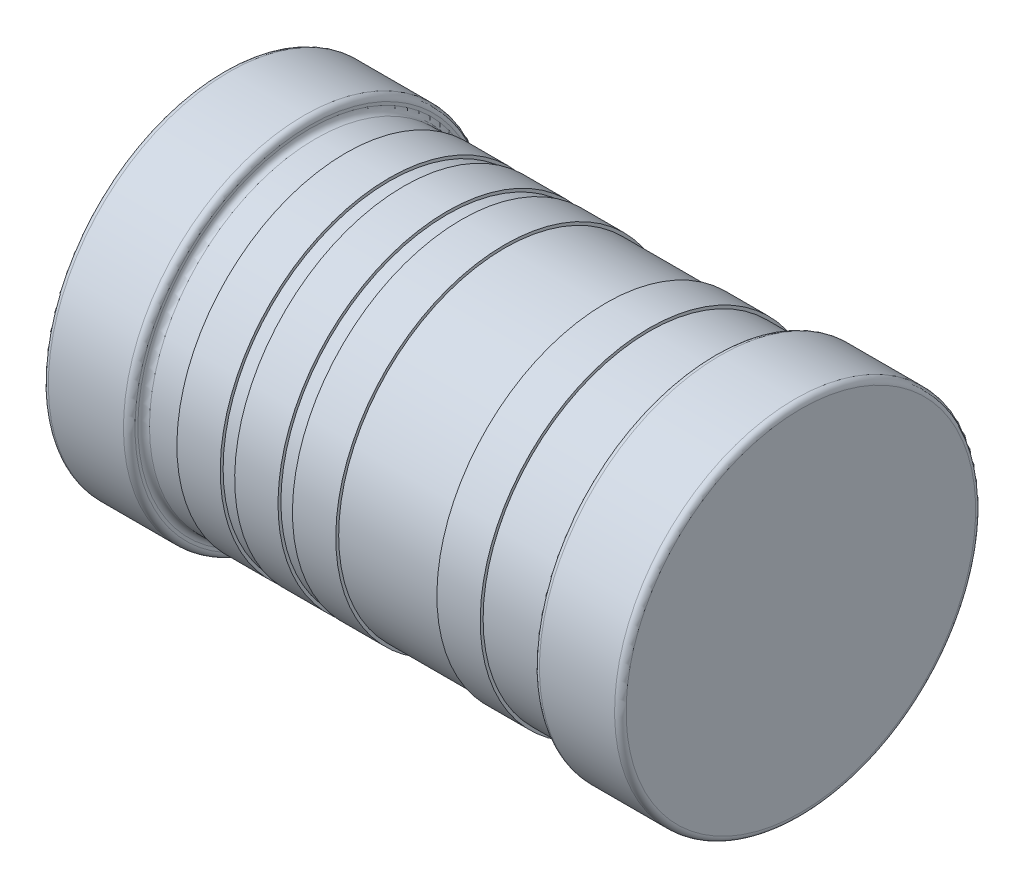
from build123d import *


with BuildPart() as part:
    # Sketch1 → Revolve1 (revolve)
    with BuildSketch(Plane.XY):
        with BuildLine():
            Line((-1, 0.625), (1, 0.625))
            Line((1, 0.625), (1, 0.02))
            ThreePointArc((1, 0.02), (0.994142136, 0.005857864), (0.98, 0))
            Line((0.98, 0), (0.72, 0))
            ThreePointArc((0.72, 0), (0.705857864, 0.005857864), (0.7, 0.02))
            Line((0.7, 0.02), (0.7, 0.03))
            ThreePointArc((0.7, 0.03), (0.694142136, 0.044142136), (0.68, 0.05))
            Line((0.68, 0.05), (0.475, 0.05))
            Line((0.475, 0.05), (0.475, 0.04))
            Line((0.475, 0.04), (0.325, 0.04))
            Line((0.325, 0.04), (0.325, 0.05))
            Line((0.325, 0.05), (-0.025, 0.05))
            Line((-0.025, 0.05), (-0.025, 0.04))
            Line((-0.025, 0.04), (-0.175, 0.04))
            Line((-0.175, 0.04), (-0.175, 0.05))
            Line((-0.175, 0.05), (-0.225, 0.05))
            Line((-0.225, 0.05), (-0.225, 0.04))
            Line((-0.225, 0.04), (-0.375, 0.04))
            Line((-0.375, 0.04), (-0.375, 0.05))
            Line((-0.375, 0.05), (-0.425, 0.05))
            Line((-0.425, 0.05), (-0.425, 0.04))
            Line((-0.425, 0.04), (-0.575, 0.04))
            Line((-0.575, 0.04), (-0.575, 0.05))
            Line((-0.575, 0.05), (-0.68, 0.05))
            ThreePointArc((-0.68, 0.05), (-0.694142136, 0.044142136), (-0.7, 0.03))
            Line((-0.7, 0.03), (-0.7, 0.02))
            ThreePointArc((-0.7, 0.02), (-0.705857864, 0.005857864), (-0.72, 0))
            Line((-0.72, 0), (-0.98, 0))
            ThreePointArc((-0.98, 0), (-0.994142136, 0.005857864), (-1, 0.02))
            Line((-1, 0.02), (-1, 0.625))
        make_face()
    revolve(axis=Axis((-1, 0.625, 0), (-1, 0, 0)))


solid = part.part
